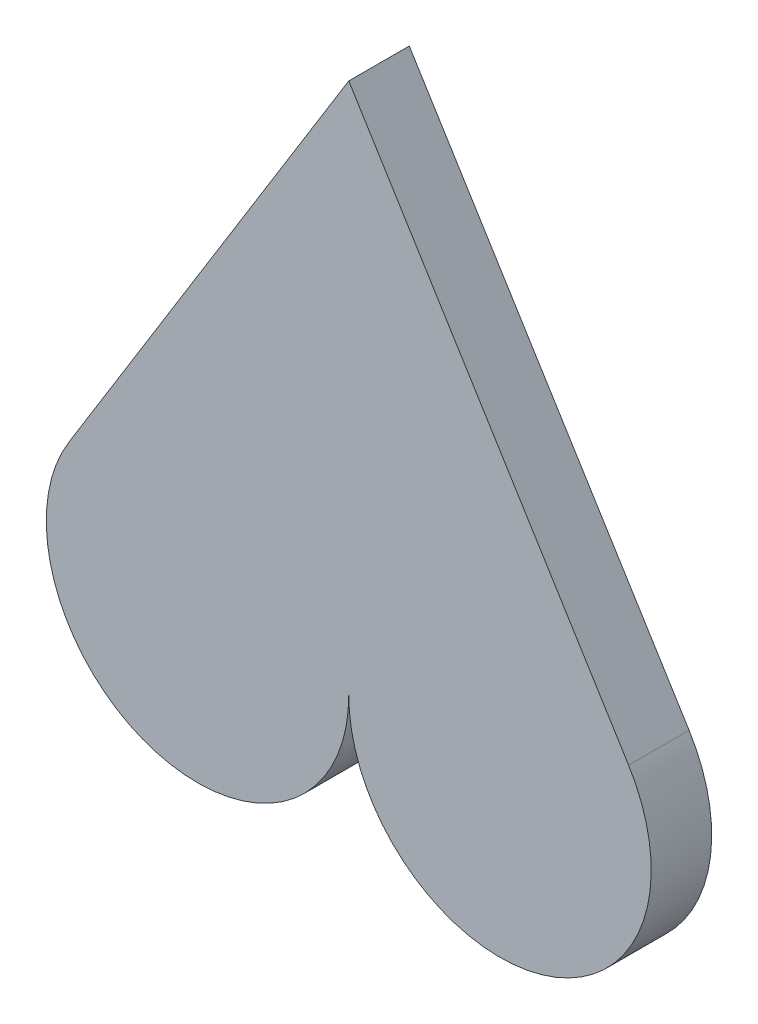
from build123d import *

# Parameters (mm, degrees)
BOSS_EXTRUDE1_DEPTH = 6


with BuildPart() as part:
    # Sketch1 → Boss-Extrude1 (new body)
    with BuildSketch(Plane(origin=(0, 0, 0), x_dir=(1, 0, 0), z_dir=(0, 0, -1))):
        with BuildLine():
            Line((-27.759328596, 44.902453019), (-0.000594147, 0.000961069))
            Line((-0.000594147, 0.000961069), (27.758140303, 44.902453019))
            ThreePointArc((27.758140303, 44.902453019), (19.099343857, 67.218890553), (-0.000594147, 52.790082274))
            ThreePointArc((-0.000594147, 52.790082274), (-19.10053215, 67.218890553), (-27.759328596, 44.902453019))
        make_face()
    extrude(amount=BOSS_EXTRUDE1_DEPTH)


solid = part.part
